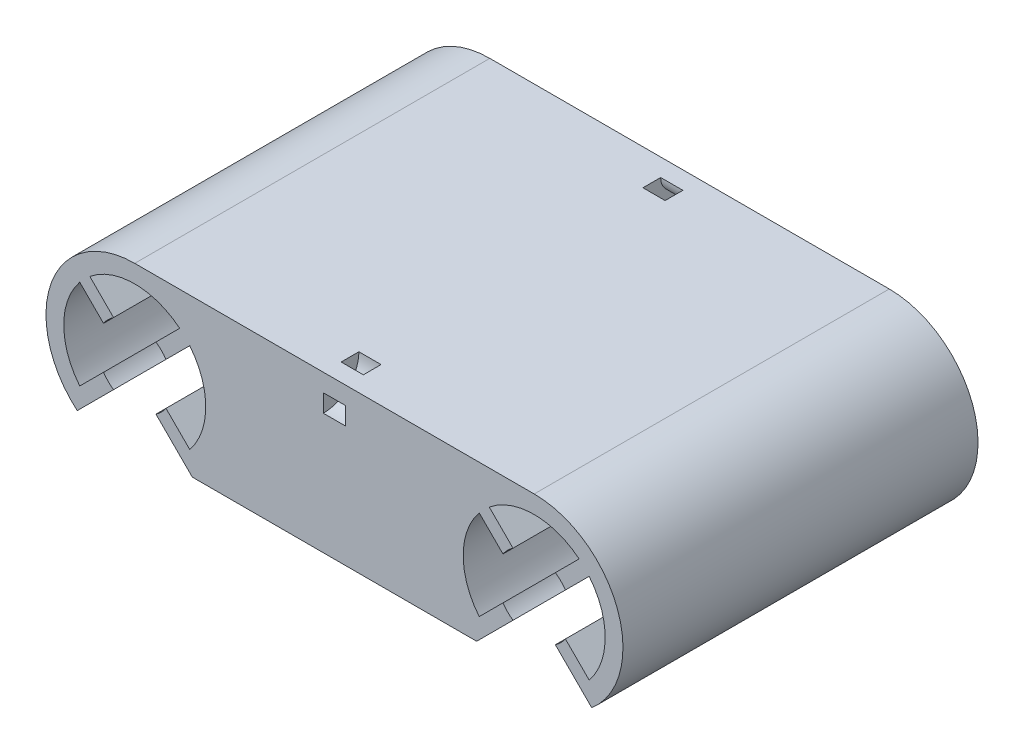
from build123d import *

# Parameters (mm, degrees)
BOSS_EXTRUDE1_DEPTH     = 40
CUT_EXTRUDE1_DEPTH      = 1.25
CUT_EXTRUDE1_DEPTH_BACK = 1.25


with BuildPart() as part:
    # Sketch1 → Boss-Extrude1 (new body)
    with BuildSketch(Plane.XY):
        with BuildLine():
            Line((-18.982831897, 2.385797253), (-16.305815663, 5.062813487))
            ThreePointArc((-16.305815663, 5.062813487), (-14.5, 0), (-16.305815663, -5.062813487))
            Line((-16.305815663, -5.062813487), (-18.982831897, -2.385797253))
            ThreePointArc((-18.982831897, -2.385797253), (-19.49479618, -3.00520382), (-20.114202747, -3.517168103))
            Line((-20.114202747, -3.517168103), (-16.01728135, -7.6140895))
            Line((-16.01728135, -7.6140895), (16.01728135, -7.6140895))
            Line((16.01728135, -7.6140895), (20.114202747, -3.517168103))
            ThreePointArc((20.114202747, -3.517168103), (19.49479618, -3.00520382), (18.982831897, -2.385797253))
            Line((18.982831897, -2.385797253), (16.305815663, -5.062813487))
            ThreePointArc((16.305815663, -5.062813487), (14.5, 0), (16.305815663, 5.062813487))
            Line((16.305815663, 5.062813487), (18.982831897, 2.385797253))
            ThreePointArc((18.982831897, 2.385797253), (19.49479618, 3.00520382), (20.114202747, 3.517168103))
            Line((20.114202747, 3.517168103), (17.437186513, 6.194184337))
            ThreePointArc((17.437186513, 6.194184337), (22.5, 8), (27.562813487, 6.194184337))
            Line((27.562813487, 6.194184337), (24.885797253, 3.517168103))
            ThreePointArc((24.885797253, 3.517168103), (25.50520382, 3.00520382), (26.017168103, 2.385797253))
            Line((26.017168103, 2.385797253), (28.694184337, 5.062813487))
            ThreePointArc((28.694184337, 5.062813487), (30.5, 0), (28.694184337, -5.062813487))
            Line((28.694184337, -5.062813487), (26.017168103, -2.385797253))
            ThreePointArc((26.017168103, -2.385797253), (25.50520382, -3.00520382), (24.885797253, -3.517168103))
            Line((24.885797253, -3.517168103), (28.98271865, -7.6140895))
            ThreePointArc((28.98271865, -7.6140895), (31.884585633, 3.453918427), (22.5, 10))
            Line((22.5, 10), (-22.5, 10))
            ThreePointArc((-22.5, 10), (-31.884585633, 3.453918427), (-28.98271865, -7.6140895))
            Line((-28.98271865, -7.6140895), (-24.885797253, -3.517168103))
            ThreePointArc((-24.885797253, -3.517168103), (-25.50520382, -3.00520382), (-26.017168103, -2.385797253))
            Line((-26.017168103, -2.385797253), (-28.694184337, -5.062813487))
            ThreePointArc((-28.694184337, -5.062813487), (-30.5, 0), (-28.694184337, 5.062813487))
            Line((-28.694184337, 5.062813487), (-26.017168103, 2.385797253))
            ThreePointArc((-26.017168103, 2.385797253), (-25.50520382, 3.00520382), (-24.885797253, 3.517168103))
            Line((-24.885797253, 3.517168103), (-27.562813487, 6.194184337))
            ThreePointArc((-27.562813487, 6.194184337), (-22.5, 8), (-17.437186513, 6.194184337))
            Line((-17.437186513, 6.194184337), (-20.114202747, 3.517168103))
            ThreePointArc((-20.114202747, 3.517168103), (-19.49479618, 3.00520382), (-18.982831897, 2.385797253))
        make_face()
    extrude(amount=BOSS_EXTRUDE1_DEPTH)

    # Sketch2 → Cut-Extrude1 (cut, two sides: drawn at the far end of the back side and taken through both)
    with BuildSketch(Plane(origin=(0, 0, 0), x_dir=(0, 0, -1), z_dir=(1, 0, 0)).offset(-CUT_EXTRUDE1_DEPTH_BACK)):
        with BuildLine():
            Line((-40, 6), (-40, 8))
            ThreePointArc((-40, 8), (-38.585786438, 8.585786438), (-38, 10))
            Line((-38, 10), (-36, 10))
            ThreePointArc((-36, 10), (-37.171572875, 7.171572875), (-40, 6))
        make_face()
        with BuildLine():
            Line((-2, 10), (-4, 10))
            ThreePointArc((-4, 10), (-2.828427125, 7.171572875), (0, 6))
            Line((0, 6), (0, 8))
            ThreePointArc((0, 8), (-1.414213562, 8.585786438), (-2, 10))
        make_face()
    extrude(amount=CUT_EXTRUDE1_DEPTH + CUT_EXTRUDE1_DEPTH_BACK, mode=Mode.SUBTRACT)


solid = part.part
